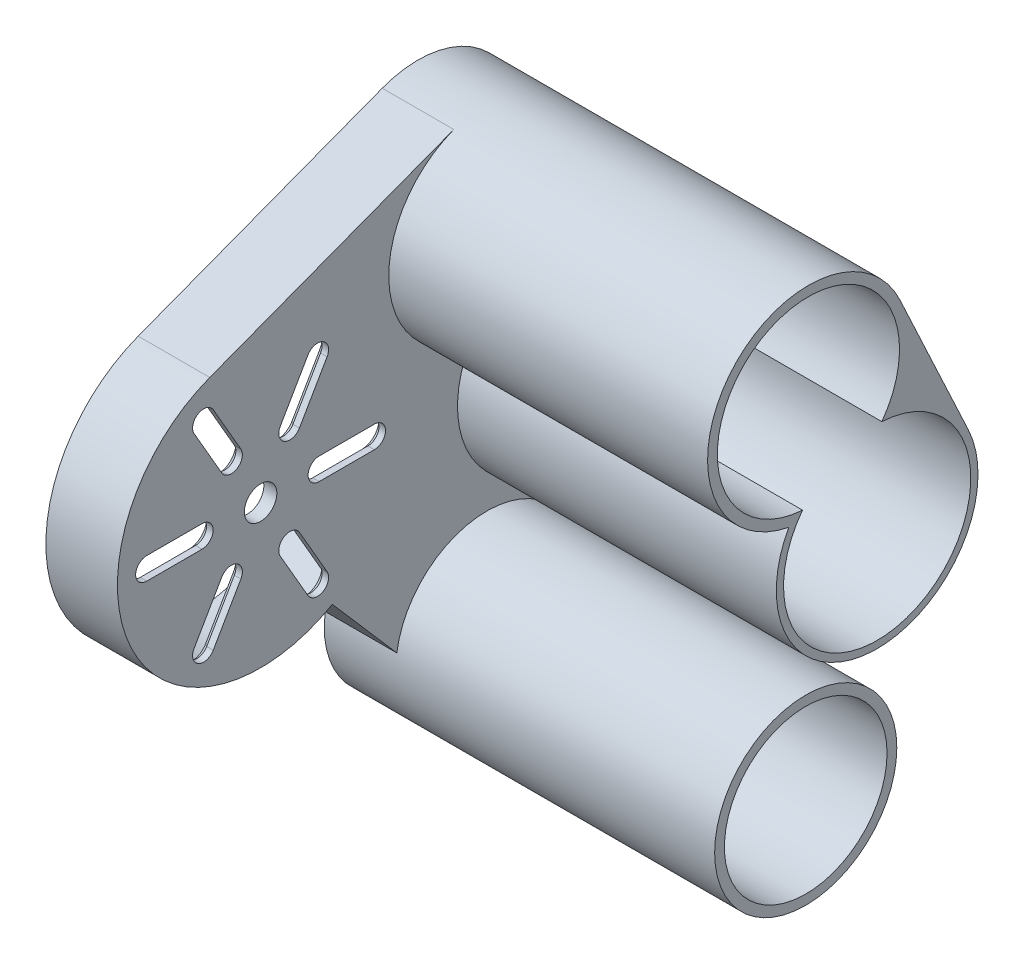
from build123d import *
from OCP.BRepFilletAPI import BRepFilletAPI_MakeChamfer
from build123d.topology import SkipClean

# Parameters (mm, degrees)
BOSS_EXTRUDE1_DEPTH      = 50
BOSS_EXTRUDE1_DEPTH_BACK = 10
SKETCH1_R                = 2.5
CUT_EXTRUDE1_DEPTH       = 9
CUT_EXTRUDE2_START       = -49
SKETCH3_R                = 2.5
SKETCH3_R_2              = 12.5
CUT_EXTRUDE2_DEPTH       = 49
CHAMFER1_SIZE            = 1
CHAMFER3_SIZE            = 0.25
CHAMFER3_SIZE2           = 0.184313844


with BuildPart() as part:
    # Sketch1 → Boss-Extrude1 (new, two sides: drawn at the far end of the back side and taken through both)
    with BuildSketch(Plane(origin=(0, 0, 0), x_dir=(0, 0, -1), z_dir=(1, 0, 0)).offset(-BOSS_EXTRUDE1_DEPTH_BACK)):
        with BuildLine():
            Line((-23.765647123, 13.461864934), (-13.852076656, 2.029771495))
            ThreePointArc((-13.852076656, 2.029771495), (-3.497090476, -13.556192615), (13.105341071, -4.924432496))
            Line((13.105341071, -4.924432496), (22.321723678, 19.603030839))
            ThreePointArc((22.321723678, 19.603030839), (26.290114693, 27.747382955), (25.028095201, 36.718776684))
            Line((25.028095201, 36.718776684), (14.462638657, 59.37647136))
            ThreePointArc((14.462638657, 59.37647136), (6.246574067, 67.186988673), (-5.088825774, 67.315862606))
            Line((-5.088825774, 67.315862606), (-42.598290861, 53.068728443))
            ThreePointArc((-42.598290861, 53.068728443), (-54.654931611, 23.055130592), (-23.765647123, 13.461864934))
        make_face()
        with Locations((-34.786596532, 32.502313304)):
            Circle(SKETCH1_R, mode=Mode.SUBTRACT)
        Circle(SKETCH1_R, mode=Mode.SUBTRACT)
        with Locations((10.980324502, 30.168193627)):
            Circle(SKETCH1_R, mode=Mode.SUBTRACT)
        with Locations((0.414867958, 52.825888303)):
            Circle(SKETCH1_R, mode=Mode.SUBTRACT)
        with BuildLine():
            Line((-43.786596532, 30.802313304), (-52.286596532, 30.802313304))
            ThreePointArc((-52.286596532, 30.802313304), (-53.986596532, 32.502313304), (-52.286596532, 34.202313304))
            Line((-52.286596532, 34.202313304), (-43.786596532, 34.202313304))
            ThreePointArc((-43.786596532, 34.202313304), (-42.086596532, 32.502313304), (-43.786596532, 30.802313304))
        make_face(mode=Mode.SUBTRACT)
        with BuildLine():
            Line((-40.758839718, 39.446541938), (-45.008839718, 46.80775787))
            ThreePointArc((-45.008839718, 46.80775787), (-44.386596532, 49.130001056), (-42.064353345, 48.50775787))
            Line((-42.064353345, 48.50775787), (-37.814353345, 41.146541938))
            ThreePointArc((-37.814353345, 41.146541938), (-38.436596532, 38.824298751), (-40.758839718, 39.446541938))
        make_face(mode=Mode.SUBTRACT)
        with BuildLine():
            Line((-31.758839718, 41.146541938), (-27.508839718, 48.50775787))
            ThreePointArc((-27.508839718, 48.50775787), (-25.186596532, 49.130001056), (-24.564353345, 46.80775787))
            Line((-24.564353345, 46.80775787), (-28.814353345, 39.446541938))
            ThreePointArc((-28.814353345, 39.446541938), (-31.136596532, 38.824298751), (-31.758839718, 41.146541938))
        make_face(mode=Mode.SUBTRACT)
        with BuildLine():
            Line((-25.786596532, 34.202313304), (-17.286596532, 34.202313304))
            ThreePointArc((-17.286596532, 34.202313304), (-15.586596532, 32.502313304), (-17.286596532, 30.802313304))
            Line((-17.286596532, 30.802313304), (-25.786596532, 30.802313304))
            ThreePointArc((-25.786596532, 30.802313304), (-27.486596532, 32.502313304), (-25.786596532, 34.202313304))
        make_face(mode=Mode.SUBTRACT)
        with BuildLine():
            Line((-28.814353345, 25.55808467), (-24.564353345, 18.196868737))
            ThreePointArc((-24.564353345, 18.196868737), (-25.186596532, 15.874625551), (-27.508839718, 16.496868737))
            Line((-27.508839718, 16.496868737), (-31.758839718, 23.85808467))
            ThreePointArc((-31.758839718, 23.85808467), (-31.136596532, 26.180327856), (-28.814353345, 25.55808467))
        make_face(mode=Mode.SUBTRACT)
        with BuildLine():
            Line((-37.814353345, 23.85808467), (-42.064353345, 16.496868737))
            ThreePointArc((-42.064353345, 16.496868737), (-44.386596532, 15.874625551), (-45.008839718, 18.196868737))
            Line((-45.008839718, 18.196868737), (-40.758839718, 25.55808467))
            ThreePointArc((-40.758839718, 25.55808467), (-38.436596532, 26.180327856), (-37.814353345, 23.85808467))
        make_face(mode=Mode.SUBTRACT)
    extrude(amount=BOSS_EXTRUDE1_DEPTH + BOSS_EXTRUDE1_DEPTH_BACK)

    # Sketch2 → Cut-Extrude1 (cut)
    with BuildSketch(Plane.ZY.offset(10)):
        with BuildLine():
            Line((27.472010023, 13.244670036), (10.007664514, 19.878112367))
            Line((10.007664514, 19.878112367), (12.484617032, 1.701275279))
            ThreePointArc((12.484617032, 1.701275279), (3.085967096, -12.216251761), (-11.794806964, -4.431989247))
            Line((-11.794806964, -4.431989247), (-21.420363252, 21.184403759))
            ThreePointArc((-21.420363252, 21.184403759), (-24.611724807, 28.196439271), (-23.538151999, 35.825388873))
            Line((-23.538151999, 35.825388873), (-13.270595294, 58.617284911))
            ThreePointArc((-13.270595294, 58.617284911), (-5.805096413, 65.854911183), (4.591717953, 66.007090733))
            Line((4.591717953, 66.007090733), (42.10118304, 51.759956571))
            ThreePointArc((42.10118304, 51.759956571), (54.044239799, 25.187726795), (27.472010023, 13.244670036))
        make_face()
    extrude(amount=-CUT_EXTRUDE1_DEPTH, mode=Mode.SUBTRACT)

    # Sketch3 → Cut-Extrude2 (cut)
    # profile 1 of 3: a face of its own
    with SkipClean():  # the faces are left unmerged after this step: merging them gives an invalid solid
        with BuildSketch(Plane(origin=(50, 0, 0), x_dir=(0, 0, -1), z_dir=(1, 0, 0)).offset(CUT_EXTRUDE2_START)):
            with BuildLine():
                Line((13.105341071, -4.924432496), (22.321723678, 19.603030839))
                ThreePointArc((22.321723678, 19.603030839), (1.900176918, 17.606310016), (-2.608851844, 37.623680616))
                ThreePointArc((-2.608851844, 37.623680616), (-15.031348835, 51.535777156), (-5.088825774, 67.315862606))
                Line((-5.088825774, 67.315862606), (-42.598290861, 53.068728443))
                ThreePointArc((-42.598290861, 53.068728443), (-54.654931611, 23.055130592), (-23.765647123, 13.461864934))
                Line((-23.765647123, 13.461864934), (-13.852076656, 2.029771495))
                ThreePointArc((-13.852076656, 2.029771495), (3.497090476, 13.556192615), (13.105341071, -4.924432496))
            make_face()
            with BuildLine():
                ThreePointArc((-40.758839718, 25.55808467), (-38.436596532, 26.180327856), (-37.814353345, 23.85808467))
                Line((-37.814353345, 23.85808467), (-42.064353345, 16.496868737))
                ThreePointArc((-42.064353345, 16.496868737), (-44.386596532, 15.874625551), (-45.008839718, 18.196868737))
                Line((-45.008839718, 18.196868737), (-40.758839718, 25.55808467))
            make_face(mode=Mode.SUBTRACT)
            with BuildLine():
                ThreePointArc((-31.758839718, 23.85808467), (-31.136596532, 26.180327856), (-28.814353345, 25.55808467))
                Line((-28.814353345, 25.55808467), (-24.564353345, 18.196868737))
                ThreePointArc((-24.564353345, 18.196868737), (-25.186596532, 15.874625551), (-27.508839718, 16.496868737))
                Line((-27.508839718, 16.496868737), (-31.758839718, 23.85808467))
            make_face(mode=Mode.SUBTRACT)
            with BuildLine():
                ThreePointArc((-43.786596532, 34.202313304), (-42.086596532, 32.502313304), (-43.786596532, 30.802313304))
                Line((-43.786596532, 30.802313304), (-52.286596532, 30.802313304))
                ThreePointArc((-52.286596532, 30.802313304), (-53.986596532, 32.502313304), (-52.286596532, 34.202313304))
                Line((-52.286596532, 34.202313304), (-43.786596532, 34.202313304))
            make_face(mode=Mode.SUBTRACT)
            with BuildLine():
                ThreePointArc((-37.814353345, 41.146541938), (-38.436596532, 38.824298751), (-40.758839718, 39.446541938))
                Line((-40.758839718, 39.446541938), (-45.008839718, 46.80775787))
                ThreePointArc((-45.008839718, 46.80775787), (-44.386596532, 49.130001056), (-42.064353345, 48.50775787))
                Line((-42.064353345, 48.50775787), (-37.814353345, 41.146541938))
            make_face(mode=Mode.SUBTRACT)
            with Locations((-34.786596532, 32.502313304)):
                Circle(SKETCH3_R, mode=Mode.SUBTRACT)
            with BuildLine():
                Line((-17.286596532, 30.802313304), (-25.786596532, 30.802313304))
                ThreePointArc((-25.786596532, 30.802313304), (-27.486596532, 32.502313304), (-25.786596532, 34.202313304))
                Line((-25.786596532, 34.202313304), (-17.286596532, 34.202313304))
                ThreePointArc((-17.286596532, 34.202313304), (-15.586596532, 32.502313304), (-17.286596532, 30.802313304))
            make_face(mode=Mode.SUBTRACT)
            with BuildLine():
                ThreePointArc((-27.508839718, 48.50775787), (-25.186596532, 49.130001056), (-24.564353345, 46.80775787))
                Line((-24.564353345, 46.80775787), (-28.814353345, 39.446541938))
                ThreePointArc((-28.814353345, 39.446541938), (-31.136596532, 38.824298751), (-31.758839718, 41.146541938))
                Line((-31.758839718, 41.146541938), (-27.508839718, 48.50775787))
            make_face(mode=Mode.SUBTRACT)
        # profile 2 of 3: a face of its own
        with BuildSketch(Plane(origin=(50, 0, 0), x_dir=(0, 0, -1), z_dir=(1, 0, 0)).offset(CUT_EXTRUDE2_START)):
            with BuildLine():
                ThreePointArc((11.700690218, 44.541552728), (-5.501787706, 65.514197321), (-0.493349523, 38.855378612))
                ThreePointArc((-0.493349523, 38.855378612), (17.062392728, 17.125156224), (11.700690218, 44.541552728))
            make_face()
            with Locations((0.414867958, 52.825888303)):
                Circle(SKETCH3_R, mode=Mode.SUBTRACT)
            with Locations((10.980324502, 30.168193627)):
                Circle(SKETCH3_R, mode=Mode.SUBTRACT)
        # profile 3 of 3: a face of its own
        with BuildSketch(Plane(origin=(50, 0, 0), x_dir=(0, 0, -1), z_dir=(1, 0, 0)).offset(CUT_EXTRUDE2_START)):
            Circle(SKETCH3_R_2)
            Circle(SKETCH3_R, mode=Mode.SUBTRACT)
        extrude(amount=CUT_EXTRUDE2_DEPTH, mode=Mode.SUBTRACT)

    # Chamfer1
    chamfer1_edges = [part.edges().sort_by_distance(p)[0] for p in [
        (-1, 21.877476703, 42.883839718),
        (-1, 30.802313304, 48.036596532),
        (-1, 32.502313304, 42.086596532),
        (-1, 34.202313304, 48.036596532),
        (-1, 32.502313304, 53.986596532),
        (-1, 43.127149904, 42.883839718),
        (-1, 38.824298751, 38.436596532),
        (-1, 44.827149904, 39.939353345),
        (-1, 49.130001056, 44.386596532),
        (-1, 44.827149904, 29.633839718),
        (-1, 38.824298751, 31.136596532),
        (-1, 43.127149904, 26.689353345),
        (-1, 49.130001056, 25.186596532),
        (-1, 34.202313304, 21.536596532),
        (-1, 32.502313304, 27.486596532),
        (-1, 30.802313304, 21.536596532),
        (-1, 32.502313304, 15.586596532),
        (-1, 21.877476703, 26.689353345),
        (-1, 26.180327856, 31.136596532),
        (-1, 20.177476703, 29.633839718),
        (-1, 15.874625551, 25.186596532),
        (-1, 20.177476703, 39.939353345),
        (-1, 26.180327856, 38.436596532),
        (-1, 15.874625551, 44.386596532),
    ]]
    chamfer(chamfer1_edges, length=CHAMFER1_SIZE)

    # Chamfer3: one chamfer whose edges measure the first distance from different faces: ONE call of the kernel's chamfer builder (chamfer() names one face for all edges)
    chamfer3_edges_1 = [part.edges().sort_by_distance(p)[0] for p in [
        (-1, 25.187726795, 54.044239799),
        (-1, 16.561391202, 18.739837269),
        (-1, 10.789693823, 11.246140773),
        (-1, -12.216251761, 3.085967096),
        (-1, 8.376207256, -16.607585108),
        (-1, 28.196439271, -24.611724807),
        (-1, 47.221336892, -18.404373646),
        (-1, 65.854911183, -5.805096413),
        (-1, 58.883523652, 23.346450497),
    ]]
    chamfer3_edges_2 = [part.edges().sort_by_distance(p)[0] for p in [
        (-5.5, 19.878112367, 10.007664514),
    ]]
    chamfer3_side_2 = [part.faces().sort_by_distance(p)[0] for p in [
        (-5.5, 10.789693823, 11.246140773),
    ]]
    chamfer3 = BRepFilletAPI_MakeChamfer(part.part.solid().wrapped)
    for e in chamfer3_edges_1:
        chamfer3.Add(CHAMFER3_SIZE, e.wrapped)
    for e in chamfer3_edges_2:
        chamfer3.Add(CHAMFER3_SIZE, CHAMFER3_SIZE2, e.wrapped, chamfer3_side_2[0].wrapped)  # the first distance lies on this face
    add(Compound.cast(chamfer3.Shape()), mode=Mode.REPLACE)


solid = part.part
